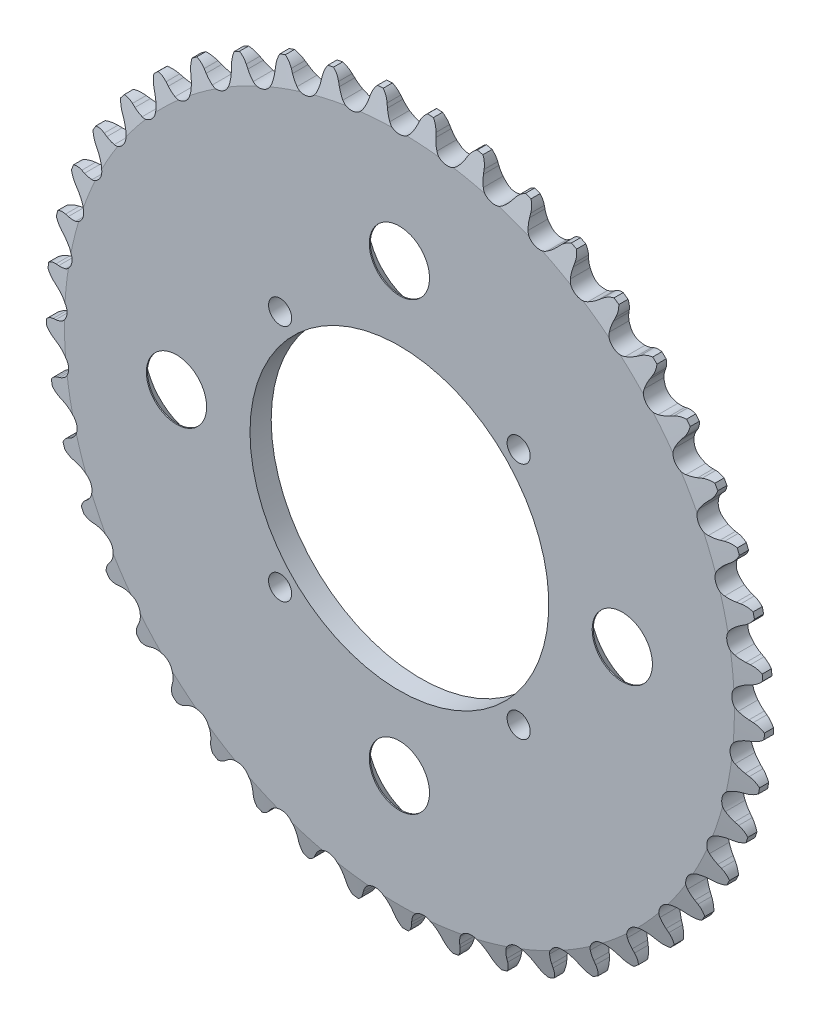
from build123d import *

# Parameters (mm, degrees)
TOOTH_CUT_NUMBER_OF_TEETH_45_DEPTH = 67.920482821
TOOTH_PATTERN_45_45_COUNT          = 45
SKETCH1_R                          = 3.96875
SKETCH1_R_2                        = 1.524
CUT_EXTRUDE1_DEPTH                 = 67.952270091
CHAMFER1_SIZE                      = 3.048
CHAMFER1_SIZE2                     = 2.649585977


with BuildPart() as part:
    # Sprocket-BaseSketch → 25 _04C_ ANSI _ISO_ Chain Number_ 3.584i (revolve)
    with BuildSketch(Plane(origin=(0, 0, 0), x_dir=(0, 0, -1), z_dir=(1, 0, 0))):
        Polygon((1.397, 19.685), (1.397, 44.134615365), (0.60325, 47.309615365), (-0.60325, 47.309615365), (-1.397, 44.134615365), (-1.397, 19.685), align=None)
    revolve(axis=Axis((0, 0, -5.588), (0, 0, 1)))

    # Tooth-Sketch → Tooth-Cut_ Number of teeth_ 45 (cut, symmetric)
    with BuildSketch(Plane.XY):
        with BuildLine():
            Line((1.960079136, 45.626665326), (2.120883977, 46.078812636))
            ThreePointArc((2.120883977, 46.078812636), (3.087332104, 47.352830394), (4.611539092, 47.836499999))
            ThreePointArc((4.611539092, 47.836499999), (0, 48.058266978), (-4.611539092, 47.836499999))
            ThreePointArc((-4.611539092, 47.836499999), (-3.087332104, 47.352830394), (-2.120883977, 46.078812636))
            Line((-2.120883977, 46.078812636), (-1.960079136, 45.626665326))
            ThreePointArc((-1.960079136, 45.626665326), (-1.704618865, 45.04654552), (-1.367361566, 44.50983661))
            ThreePointArc((-1.367361566, 44.50983661), (0, 43.818133808), (1.367361566, 44.50983661))
            ThreePointArc((1.367361566, 44.50983661), (1.704618865, 45.04654552), (1.960079136, 45.626665326))
        make_face()
    tooth_cut_number_of_teeth_45 = extrude(amount=TOOTH_CUT_NUMBER_OF_TEETH_45_DEPTH, both=True, mode=Mode.SUBTRACT)

    # Tooth Pattern_ 45 _ 45: Tooth-Cut_ Number of teeth_ 45 ×45 about axis
    tooth_pattern_45_45_axis = Axis((0, 0, -88.99), (0, 0, 1))
    for i in range(1, TOOTH_PATTERN_45_45_COUNT):
        add(tooth_cut_number_of_teeth_45.rotate(tooth_pattern_45_45_axis, i * 360 / TOOTH_PATTERN_45_45_COUNT), mode=Mode.SUBTRACT)

    # Sketch1 → Cut-Extrude1 (cut, through all)
    with BuildSketch(Plane(origin=(0, 0, -1.397), x_dir=(-1, 0, 0), z_dir=(0, 0, -1))):
        with Locations((29.36875, 0)):
            Circle(SKETCH1_R)
        with Locations((0, -29.36875)):
            Circle(SKETCH1_R)
        with Locations((-29.36875, 0)):
            Circle(SKETCH1_R)
        with Locations((0, 29.36875)):
            Circle(SKETCH1_R)
        with Locations((15.715448212, -15.715448212)):
            Circle(SKETCH1_R_2)
        with Locations((-15.715448212, -15.715448212)):
            Circle(SKETCH1_R_2)
        with Locations((-15.715448212, 15.715448212)):
            Circle(SKETCH1_R_2)
        with Locations((15.715448212, 15.715448212)):
            Circle(SKETCH1_R_2)
    extrude(amount=-CUT_EXTRUDE1_DEPTH, mode=Mode.SUBTRACT)

    # Chamfer1
    chamfer1_edges = [part.edges().sort_by_distance(p)[0] for p in [
        (3.96875, -29.36875, -1.397),
        (-25.4, 0, -1.397),
        (3.96875, 29.36875, -1.397),
        (33.3375, 0, -1.397),
    ]]
    chamfer1_side = [part.faces().sort_by_distance(p)[0] for p in [
        (-2.991602334, 42.781906549, -1.397),
    ]]
    chamfer(chamfer1_edges, length=CHAMFER1_SIZE, length2=CHAMFER1_SIZE2, reference=chamfer1_side[0])


solid = part.part
